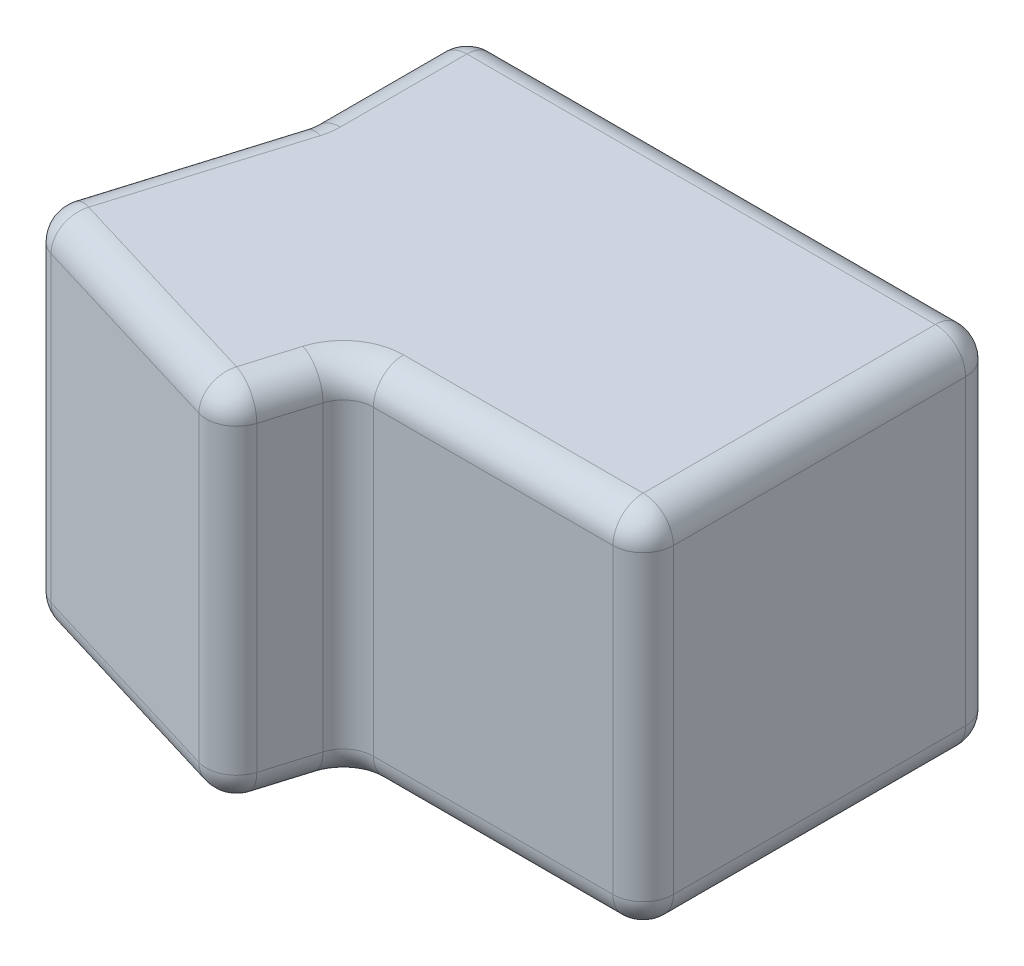
from build123d import *

# Parameters (mm, degrees)
BOSS_EXTRUDE1_DEPTH             = 36
FILLET1_R                       = 3
TAP_DRILL_FOR_M3X0_5_TAP1_D     = 2.5
TAP_DRILL_FOR_M3X0_5_TAP1_DEPTH = 3
TAP_DRILL_FOR_M3X0_5_TAP1_TIP   = 0.751075774


with BuildPart() as part:
    # Sketch1 → Boss-Extrude1 (new body)
    with BuildSketch(Plane(origin=(0, 0, 0), x_dir=(1, 0, 0), z_dir=(0, 1, 0))):
        with BuildLine():
            Line((0, 3), (0, 32))
            ThreePointArc((0, 32), (-0.878679656, 34.121320344), (-3, 35))
            Line((-3, 35), (-49.5, 35))
            ThreePointArc((-49.5, 35), (-51.621320344, 34.121320344), (-52.5, 32))
            Line((-52.5, 32), (-52.5, 19.444534932))
            ThreePointArc((-52.5, 19.444534932), (-52.53240259, 19.004801361), (-52.628910409, 18.574566795))
            Line((-52.628910409, 18.574566795), (-57.971756527, 0.941978638))
            ThreePointArc((-57.971756527, 0.941978638), (-57.745994224, -1.34299605), (-55.970635073, -2.799079091))
            Line((-55.970635073, -2.799079091), (-34.915978072, -9.178845431))
            ThreePointArc((-34.915978072, -9.178845431), (-32.631003385, -8.953083129), (-31.174920343, -7.177723978))
            Line((-31.174920343, -7.177723978), (-29.645420421, -2.130031863))
            ThreePointArc((-29.645420421, -2.130031863), (-28.561800492, -0.590653158), (-26.77433083, 0))
            Line((-26.77433083, 0), (-3, 0))
            ThreePointArc((-3, 0), (-0.878679656, 0.878679656), (0, 3))
        make_face()
    extrude(amount=BOSS_EXTRUDE1_DEPTH)

    # Fillet1
    fillet1_edges = [part.edges().sort_by_distance(p)[0] for p in [
        (-0.878679656, 36, -34.121320344),
        (-14.887165415, 0, 0),
        (-28.561800492, 0, 0.590653158),
        (-26.25, 36, -35),
        (-30.410170382, 0, 4.65387792),
        (-32.631003385, 0, 8.953083129),
        (-45.443306572, 0, 5.988962261),
        (-57.745994224, 0, 1.34299605),
        (-55.300333468, 0, -9.758272716),
        (-52.53240259, 0, -19.004801361),
        (-52.5, 0, -25.722267466),
        (-51.621320344, 36, -34.121320344),
        (-51.621320344, 0, -34.121320344),
        (-26.25, 0, -35),
        (-0.878679656, 0, -34.121320344),
        (0, 0, -17.5),
        (-0.878679656, 0, -0.878679656),
        (-52.5, 36, -25.722267466),
        (-52.53240259, 36, -19.004801361),
        (-55.300333468, 36, -9.758272716),
        (-57.745994224, 36, 1.34299605),
        (-45.443306572, 36, 5.988962261),
        (-32.631003385, 36, 8.953083129),
        (-30.410170382, 36, 4.65387792),
        (-0.878679656, 36, -0.878679656),
        (-28.561800492, 36, 0.590653158),
        (-14.887165415, 36, 0),
        (0, 36, -17.5),
    ]]
    fillet(fillet1_edges, radius=FILLET1_R)

    # Tap Drill for M3x0.5 Tap1
    with Locations(Plane(origin=(0, 0, 0), x_dir=(-1, 0, 0), z_dir=(0, -1, 0))):
        with Locations((7, 25), (45, 25)):
            Hole(TAP_DRILL_FOR_M3X0_5_TAP1_D / 2, depth=TAP_DRILL_FOR_M3X0_5_TAP1_DEPTH)
            with Locations((0, 0, -(TAP_DRILL_FOR_M3X0_5_TAP1_DEPTH + TAP_DRILL_FOR_M3X0_5_TAP1_TIP / 2))):  # 118° drill point
                Cone(0, TAP_DRILL_FOR_M3X0_5_TAP1_D / 2, TAP_DRILL_FOR_M3X0_5_TAP1_TIP, mode=Mode.SUBTRACT)


solid = part.part
